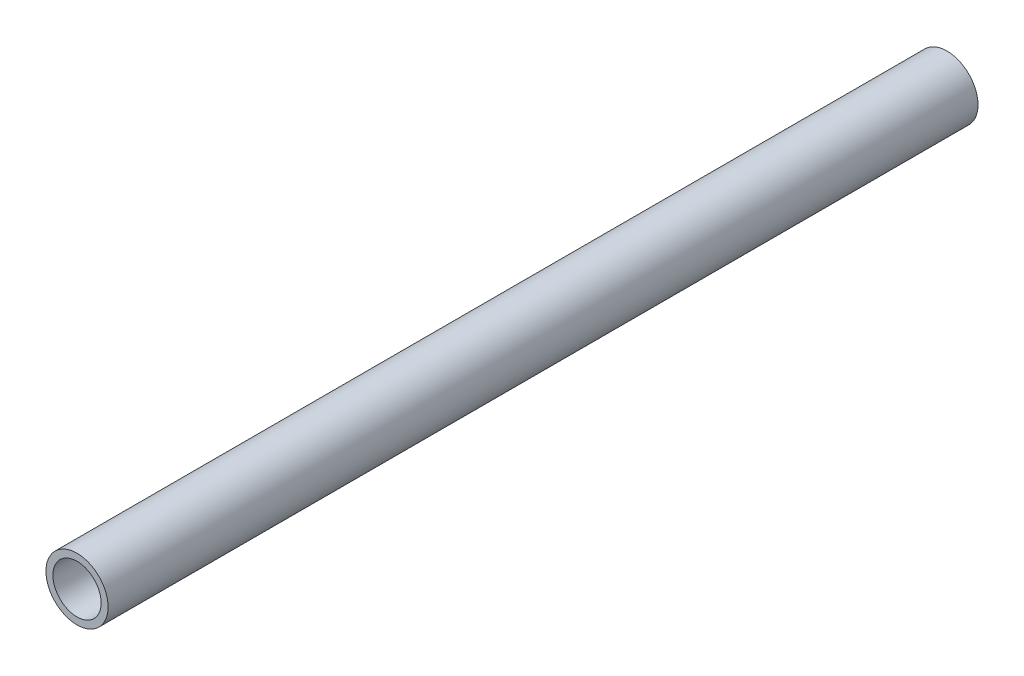
from build123d import *

# Parameters (mm, degrees)
SKETCH_1_R      = 12.5
SKETCH_1_R_2    = 9.7
EXTRUDE_1_DEPTH = 175


with BuildPart() as part:
    # 草图1 → 凸台-拉伸1 (new body, symmetric)
    with BuildSketch(Plane.XY):
        Circle(SKETCH_1_R)
        Circle(SKETCH_1_R_2, mode=Mode.SUBTRACT)
    extrude(amount=EXTRUDE_1_DEPTH, both=True)


solid = part.part
